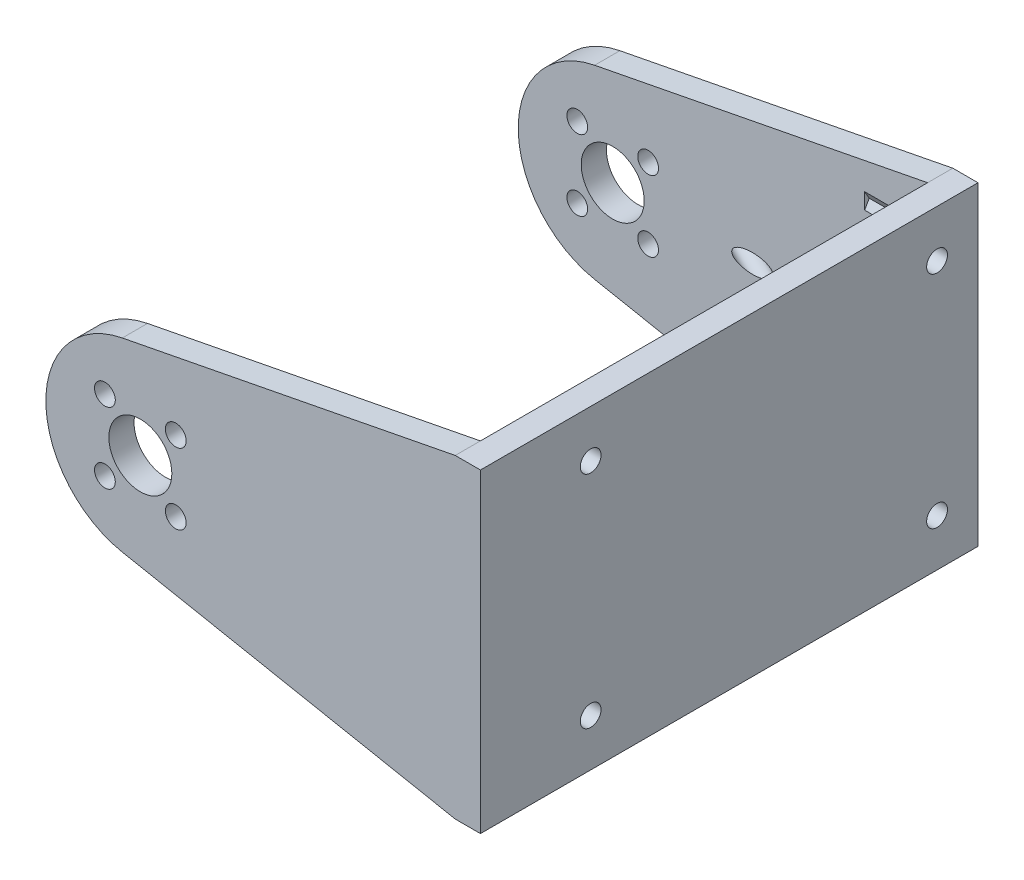
from build123d import *

# Parameters (mm, degrees)
SKETCH_2_W               = 79
SKETCH_2_H               = 50
EXTRUDE_1_DEPTH          = 4
SKETCH_3_R               = 5
SKETCH_3_R_2             = 1.65
EXTRUDE_2_DEPTH          = 4
SKETCH_4_W               = 19.2
SKETCH_4_H               = 25.2
SKETCH_4_W_2             = 16
SKETCH_4_H_2             = 22
EXTRUDE_3_DEPTH          = 6
SKETCH_5_R               = 1.1
EXTRUDE_4_DEPTH          = 2
SKETCH_6_R               = 1.15
CUT_EXTRUDE_1_DEPTH      = 2
SKETCH_7_R               = 1.5
CUT_EXTRUDE_2_DEPTH      = 69
SKETCH_8_R               = 1.65
CUT_EXTRUDE_3_DEPTH      = 5
CUT_EXTRUDE_4_DEPTH      = 10
CUT_EXTRUDE_4_DEPTH_BACK = 0.7


with BuildPart() as part:
    # 草图2 → 凸台-拉伸1 (new body)
    with BuildSketch(Plane(origin=(0, 0, 0), x_dir=(0, 0, -1), z_dir=(1, 0, 0))):
        Rectangle(SKETCH_2_W, SKETCH_2_H)
    extrude(amount=EXTRUDE_1_DEPTH)

    # 草图3 → 凸台-拉伸2 (add)
    with BuildSketch(Plane.XY.offset(39.5)):
        with BuildLine():
            Line((-52.862197769, 14.724395537), (0, 25))
            Line((0, 25), (0, -25))
            Line((0, -25), (-52.862197769, -14.724395537))
            ThreePointArc((-52.862197769, -14.724395537), (-65, 0), (-52.862197769, 14.724395537))
        make_face()
        with Locations((-50, 0)):
            Circle(SKETCH_3_R, mode=Mode.SUBTRACT)
        with Locations((-55.625, 5.625)):
            Circle(SKETCH_3_R_2, mode=Mode.SUBTRACT)
        with Locations((-44.375, 5.625)):
            Circle(SKETCH_3_R_2, mode=Mode.SUBTRACT)
        with Locations((-44.375, -5.625)):
            Circle(SKETCH_3_R_2, mode=Mode.SUBTRACT)
        with Locations((-55.625, -5.625)):
            Circle(SKETCH_3_R_2, mode=Mode.SUBTRACT)
    extrude_2 = extrude(amount=-EXTRUDE_2_DEPTH)

    # 镜向1: 凸台-拉伸2 across plane
    add(extrude_2.mirror(Plane.XY))

    # 草图4 → 凸台-拉伸3 (add)
    with BuildSketch(Plane.ZY):
        Rectangle(SKETCH_4_W, SKETCH_4_H)
        Rectangle(SKETCH_4_W_2, SKETCH_4_H_2, mode=Mode.SUBTRACT)
    extrude(amount=EXTRUDE_3_DEPTH)

    # 草图5 → 凸台-拉伸4 (add)
    with BuildSketch(Plane.ZY.offset(6)):
        with BuildLine():
            Line((12, 9.25), (9.6, 9.25))
            Line((9.6, 9.25), (9.6, 4.75))
            Line((9.6, 4.75), (12, 4.75))
            ThreePointArc((12, 4.75), (14.25, 7), (12, 9.25))
        make_face()
        with Locations((12, 7)):
            Circle(SKETCH_5_R, mode=Mode.SUBTRACT)
        with BuildLine():
            Line((9.6, -9.25), (9.6, -4.75))
            Line((9.6, -4.75), (12, -4.75))
            ThreePointArc((12, -4.75), (14.25, -7), (12, -9.25))
            Line((12, -9.25), (9.6, -9.25))
        make_face()
        with Locations((12, -7)):
            Circle(SKETCH_5_R, mode=Mode.SUBTRACT)
        with BuildLine():
            Line((-12, -9.25), (-9.6, -9.25))
            Line((-9.6, -9.25), (-9.6, -4.75))
            Line((-9.6, -4.75), (-12, -4.75))
            ThreePointArc((-12, -4.75), (-14.25, -7), (-12, -9.25))
        make_face()
        with Locations((-12, -7)):
            Circle(SKETCH_5_R, mode=Mode.SUBTRACT)
        with BuildLine():
            Line((-9.6, 9.25), (-9.6, 4.75))
            Line((-9.6, 4.75), (-12, 4.75))
            ThreePointArc((-12, 4.75), (-14.25, 7), (-12, 9.25))
            Line((-12, 9.25), (-9.6, 9.25))
        make_face()
        with Locations((-12, 7)):
            Circle(SKETCH_5_R, mode=Mode.SUBTRACT)
    extrude(amount=-EXTRUDE_4_DEPTH)

    # 草图6 → 切除-拉伸1 (cut)
    with BuildSketch(Plane.XY.offset(-8)):
        with Locations((-6, 0)):
            Circle(SKETCH_6_R)
    extrude(amount=-CUT_EXTRUDE_1_DEPTH, mode=Mode.SUBTRACT)

    # 草图7 → 切除-拉伸2 (cut)
    with BuildSketch(Plane(origin=(-12.802515134, 0, -6.523207278), x_dir=(0, 1, 0), z_dir=(0.891006524, 0, 0.4539905))):
        with Locations((0, -19.010719704)):
            Circle(SKETCH_7_R)
    extrude(amount=-CUT_EXTRUDE_2_DEPTH, mode=Mode.SUBTRACT)

    # 草图8 → 切除-拉伸3 (cut, through all)
    with BuildSketch(Plane.ZY):
        with Locations((-33, 17.5)):
            Circle(SKETCH_8_R)
        with Locations((22, 17.5)):
            Circle(SKETCH_8_R)
        with Locations((22, -17.5)):
            Circle(SKETCH_8_R)
        with Locations((-33, -17.5)):
            Circle(SKETCH_8_R)
    extrude(amount=-CUT_EXTRUDE_3_DEPTH, mode=Mode.SUBTRACT)

    # 草图9 → 切除-拉伸4 (cut, two sides)
    with BuildSketch(Plane.ZY) as cut_extrude_4_sk:
        Polygon((-31.383419246, 14.7), (-29.766838493, 17.5), (-31.383419246, 20.3), (-34.616580754, 20.3), (-36.233161507, 17.5), (-34.616580754, 14.7), align=None)
        Polygon((-29.766838493, -17.5), (-31.383419246, -14.7), (-34.616580754, -14.7), (-36.233161507, -17.5), (-34.616580754, -20.3), (-31.383419246, -20.3), align=None)
        Polygon((23.616580754, -14.7), (20.383419246, -14.7), (18.766838493, -17.5), (20.383419246, -20.3), (23.616580754, -20.3), (25.233161507, -17.5), align=None)
        Polygon((25.233161507, 17.5), (23.616580754, 20.3), (20.383419246, 20.3), (18.766838493, 17.5), (20.383419246, 14.7), (23.616580754, 14.7), align=None)
    extrude(amount=CUT_EXTRUDE_4_DEPTH, mode=Mode.SUBTRACT)
    extrude(cut_extrude_4_sk.sketch, amount=-CUT_EXTRUDE_4_DEPTH_BACK, mode=Mode.SUBTRACT)


solid = part.part
